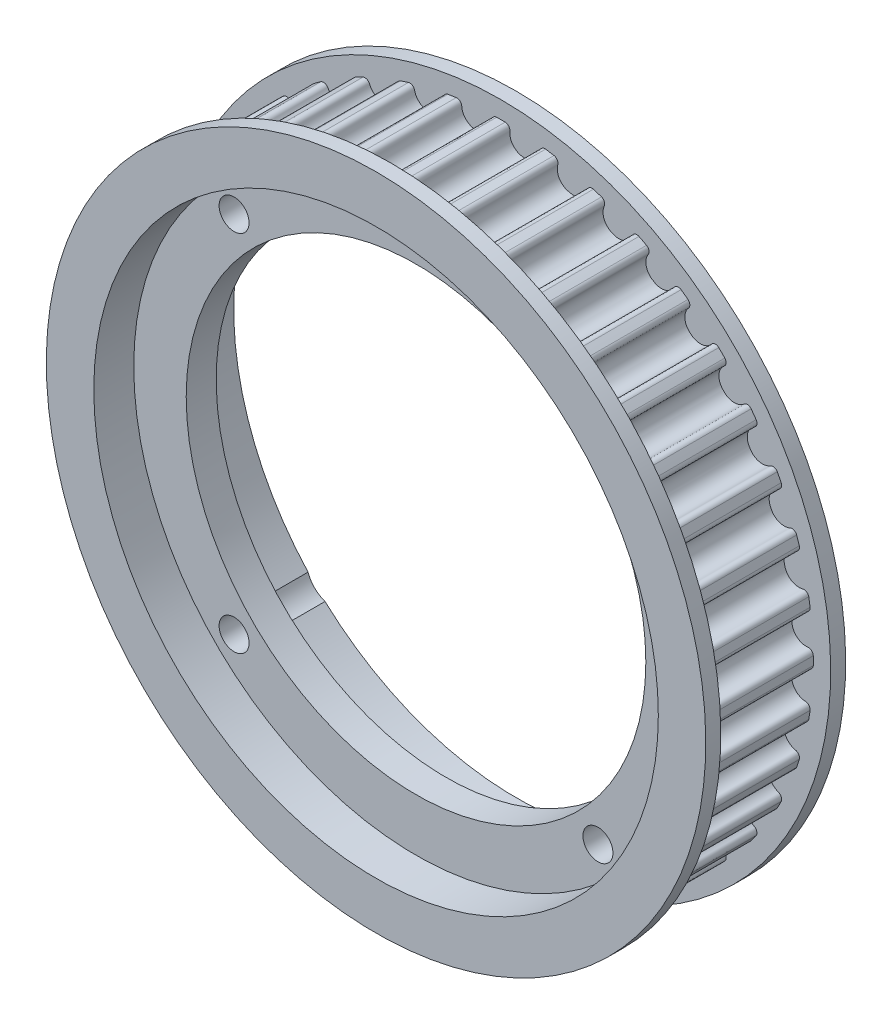
from build123d import *

# Parameters (mm, degrees)
CUT_EXTRUDE_01_DEPTH      = 5.5
PATTERN_CIRCULAR_01_COUNT = 40
SKETCH_7_R                = 23
SKETCH_7_R_2              = 1.5
CUT_EXTRUDE_4_DEPTH       = 15
SKETCH_10_R               = 28.25
CUT_EXTRUDE_5_DEPTH       = 4
SKETCH_11_R               = 28.25
CUT_EXTRUDE_6_DEPTH       = 7
SKETCH_12_R               = 2.75
CUT_EXTRUDE_7_DEPTH       = 7


with BuildPart() as part:
    # Sketch 01 → 同步带轮01 (revolve)
    with BuildSketch(Plane(origin=(0, 0, 0), x_dir=(0, 0, -1), z_dir=(1, 0, 0))):
        Polygon((7, 0), (7, 33), (5.5, 33), (5.5, 31.259474731), (-5.5, 31.259474731), (-5.5, 33), (-7, 33), (-7, 0), align=None)
    revolve(axis=Axis((0, 0, 7), (0, 0, 1)))

    # Sketch 01 2 → 齿拉伸切除同步带轮01 (cut, symmetric)
    with BuildSketch(Plane.XY):
        with BuildLine():
            ThreePointArc((30.936913825, 4.479958382), (31.163238234, 2.452600039), (31.256848972, 0.414796904))
            add(Edge.make_bspline(
                [(31.256848972, 0.414796904), (31.25649856, 0.441398238), (31.252694742, 0.481255627), (31.241192899, 0.533250036), (31.229410355, 0.571410961), (31.214550062, 0.608481939), (31.196711421, 0.644215232), (31.176013626, 0.678372028), (31.152595007, 0.710724056), (31.126612072, 0.741055105), (31.098238467, 0.76916247), (31.067663815, 0.794858309), (31.035092448, 0.817970882), (31.000742041, 0.838345784), (30.964842174, 0.855846625), (30.927632712, 0.870357278), (30.889362542, 0.88177766), (30.850286632, 0.890043049), (30.810669087, 0.895054909), (30.770763642, 0.89694133), (30.723670084, 0.894751492), (30.652559613, 0.888066914), (30.556780232, 0.884157511), (30.443886402, 0.888721022), (30.331693179, 0.902043417), (30.220891753, 0.924145699), (30.112164718, 0.954864087), (30.006181893, 0.994016738), (29.903596191, 1.041360468), (29.805039597, 1.096604144), (29.711119274, 1.159407293), (29.622413824, 1.22938305), (29.539469717, 1.306100316), (29.462797954, 1.389086474), (29.392870799, 1.477830274), (29.330119332, 1.571785039), (29.274929053, 1.670371834), (29.227644008, 1.772983758), (29.188540409, 1.878986995), (29.157915473, 1.987734738), (29.13574769, 2.098533782), (29.125691474, 2.186796852), (29.120908705, 2.25123959), (29.117671082, 2.291610413), (29.114553456, 2.33199068), (29.109196277, 2.39638821), (29.105321298, 2.485137754), (29.109883369, 2.598040483), (29.123119366, 2.710240157), (29.145158975, 2.821055469), (29.175809821, 2.92980108), (29.214898244, 3.03580777), (29.262179373, 3.138422288), (29.31736302, 3.237012522), (29.380108931, 3.330971089), (29.450030634, 3.419719155), (29.526697353, 3.502709984), (29.609636784, 3.579432297), (29.698337968, 3.64941348), (29.792254478, 3.71222227), (29.890807655, 3.767472253), (29.993390665, 3.814821102), (30.099370383, 3.85398443), (30.20809824, 3.884693692), (30.318888268, 3.906861504), (30.414100012, 3.917983429), (30.485380693, 3.922505277), (30.532237017, 3.927709456), (30.571356059, 3.935815239), (30.609701819, 3.946962944), (30.647003647, 3.96123939), (30.683016107, 3.978505942), (30.717497492, 3.998658788), (30.750217638, 4.021560141), (30.780957798, 4.047057782), (30.809512554, 4.074981084), (30.835691067, 4.105143495), (30.859318385, 4.137343421), (30.880236606, 4.171365671), (30.89830593, 4.206982871), (30.913405601, 4.243956989), (30.9254347, 4.282040923), (30.934312859, 4.320980159), (30.939980657, 4.360514455), (30.943207175, 4.413668012), (30.940729093, 4.453629738), (30.936913825, 4.479958382)],
                knots=[0, 0, 0, 0, 0.012475647, 0.018713471, 0.024951294, 0.031189118, 0.037426941, 0.043664765, 0.049902589, 0.056140412, 0.062378236, 0.068616059, 0.074853883, 0.081091706, 0.08732953, 0.093567353, 0.099805177, 0.106043001, 0.112280824, 0.118518648, 0.124756471, 0.134376181, 0.152024115, 0.169672048, 0.187319982, 0.204967916, 0.22261585, 0.240263783, 0.257911717, 0.275559651, 0.293207585, 0.310855518, 0.328503452, 0.346151386, 0.36379932, 0.381447253, 0.399095187, 0.416743121, 0.434391055, 0.452038988, 0.469686922, 0.487334856, 0.493667428, 0.5, 0.506332572, 0.512665144, 0.530313078, 0.547961012, 0.565608945, 0.583256879, 0.600904813, 0.618552747, 0.63620068, 0.653848614, 0.671496548, 0.689144482, 0.706792415, 0.724440349, 0.742088283, 0.759736217, 0.77738415, 0.795032084, 0.812680018, 0.830327952, 0.847975885, 0.865623819, 0.875243529, 0.881481352, 0.887719176, 0.893956999, 0.900194823, 0.906432647, 0.91267047, 0.918908294, 0.925146117, 0.931383941, 0.937621764, 0.943859588, 0.950097411, 0.956335235, 0.962573059, 0.968810882, 0.975048706, 0.981286529, 0.987524353, 1, 1, 1, 1], degree=3))
        make_face()
    cut_extrude_01 = extrude(amount=CUT_EXTRUDE_01_DEPTH, both=True, mode=Mode.SUBTRACT)

    # 齿形同步带轮01: 齿拉伸切除同步带轮01 ×40 about axis
    pattern_circular_01_axis = Axis((0, 0, 55), (0, 0, -1))
    for i in range(1, PATTERN_CIRCULAR_01_COUNT):
        add(cut_extrude_01.rotate(pattern_circular_01_axis, i * 360 / PATTERN_CIRCULAR_01_COUNT), mode=Mode.SUBTRACT)

    # 草图7 → 切除-拉伸4 (cut, through all)
    with BuildSketch(Plane.XY.offset(7)):
        Circle(SKETCH_7_R)
        with Locations((-18.207999616, 18.207999616)):
            Circle(SKETCH_7_R_2)
        with Locations((18.207999616, 18.207999616)):
            Circle(SKETCH_7_R_2)
        with Locations((18.207999616, -18.207999616)):
            Circle(SKETCH_7_R_2)
        with Locations((-18.207999616, -18.207999616)):
            Circle(SKETCH_7_R_2)
    extrude(amount=-CUT_EXTRUDE_4_DEPTH, mode=Mode.SUBTRACT)

    # 草图10 → 切除-拉伸5 (cut)
    with BuildSketch(Plane.XY.offset(7)):
        Circle(SKETCH_10_R)
    extrude(amount=-CUT_EXTRUDE_5_DEPTH, mode=Mode.SUBTRACT)

    # 草图11 → 切除-拉伸6 (cut)
    with BuildSketch(Plane(origin=(0, 0, -7), x_dir=(-1, 0, 0), z_dir=(0, 0, -1))):
        Circle(SKETCH_11_R)
    extrude(amount=-CUT_EXTRUDE_6_DEPTH, mode=Mode.SUBTRACT)

    # 草图12 → 切除-拉伸7 (cut)
    with BuildSketch(Plane(origin=(0, 0, -7), x_dir=(-1, 0, 0), z_dir=(0, 0, -1))):
        with Locations((-18.207999616, 18.207999616)):
            Circle(SKETCH_12_R)
        with Locations((-18.207999616, -18.207999616)):
            Circle(SKETCH_12_R)
        with Locations((18.207999616, -18.207999616)):
            Circle(SKETCH_12_R)
        with Locations((18.207999616, 18.207999616)):
            Circle(SKETCH_12_R)
    extrude(amount=-CUT_EXTRUDE_7_DEPTH, mode=Mode.SUBTRACT)


solid = part.part
